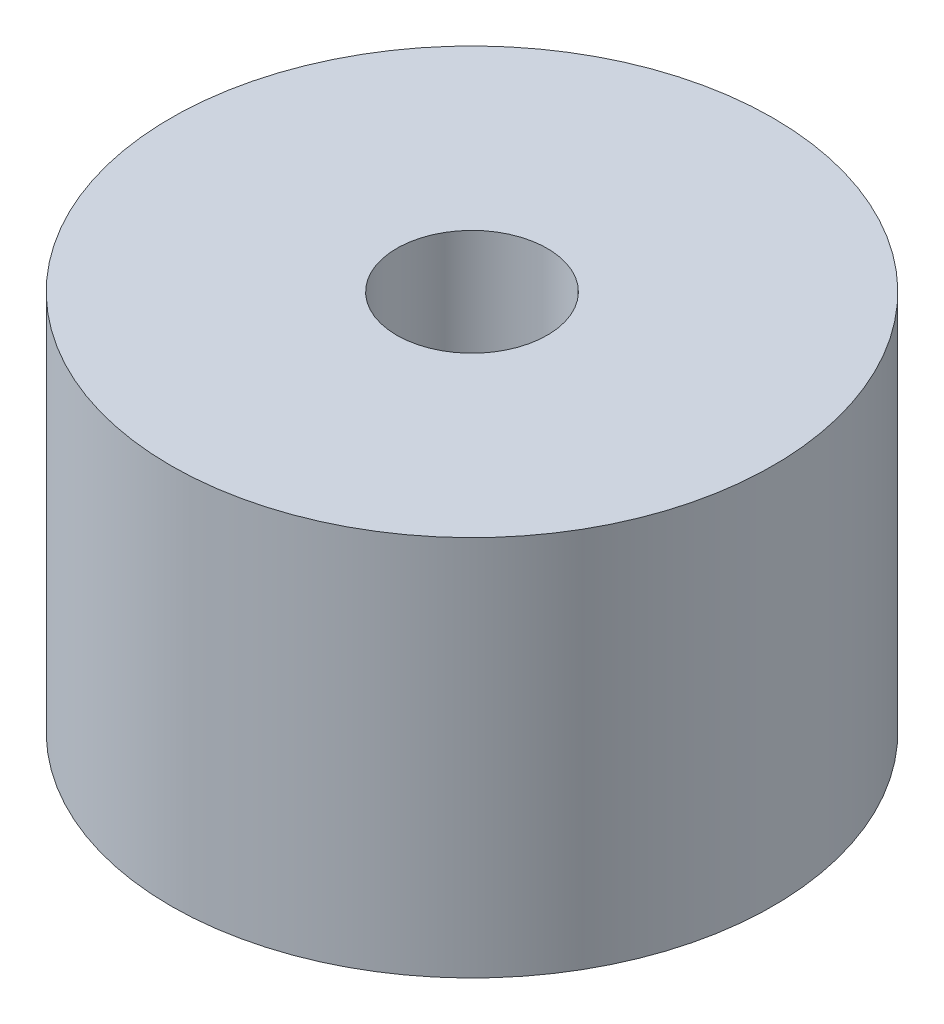
from build123d import *

# Parameters (mm, degrees)
SKICA1_R                 = 6
P_IDAT_VYSUNUT_M1_DEPTH  = 7.6
SKICA2_R                 = 1.5
ODEBRAT_VYSUNUT_M1_DEPTH = 4


with BuildPart() as part:
    # Skica1 → Přidat vysunutím1 (new body)
    with BuildSketch(Plane(origin=(0, 0, 0), x_dir=(1, 0, 0), z_dir=(0, 1, 0))):
        Circle(SKICA1_R)
    extrude(amount=P_IDAT_VYSUNUT_M1_DEPTH)

    # Skica2 → Odebrat vysunutím1 (cut)
    with BuildSketch(Plane(origin=(0, 7.6, 0), x_dir=(1, 0, 0), z_dir=(0, 1, 0))):
        Circle(SKICA2_R)
    extrude(amount=-ODEBRAT_VYSUNUT_M1_DEPTH, mode=Mode.SUBTRACT)


solid = part.part
